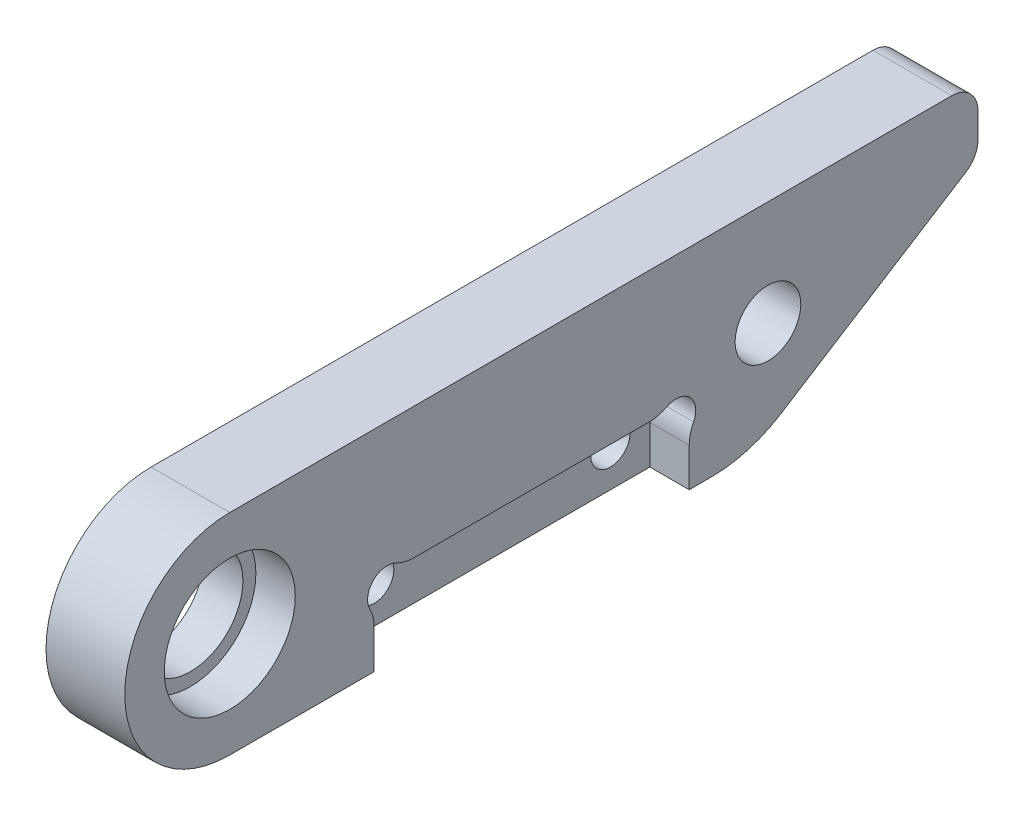
from build123d import *

# Parameters (mm, degrees)
SKETCH27_R          = 4
SKETCH27_R_2        = 2.5
BOSS_EXTRUDE1_DEPTH = 6
SKETCH33_R          = 4.99
CUT_EXTRUDE2_DEPTH  = 3
SKETCH34_W          = 24
SKETCH34_H          = 6
CUT_EXTRUDE3_DEPTH  = 3
SKETCH35_R          = 1.5
CUT_EXTRUDE4_DEPTH  = 3
FILLET1_R           = 3
CUT_EXTRUDE5_REACH  = 5
SKETCH36_R          = 1.5
FILLET3_R           = 2
FILLET4_R           = 10


with BuildPart() as part:
    # Sketch27 → Boss-Extrude1 (new body)
    with BuildSketch(Plane(origin=(0, 0, 0), x_dir=(0, 0, -1), z_dir=(1, 0, 0))):
        with BuildLine():
            Line((9, 50), (66, 50))
            Line((66, 50), (66, 45))
            Line((66, 45), (48.564398788, 34))
            Line((48.564398788, 34), (9, 34))
            ThreePointArc((9, 34), (1, 42), (9, 50))
        make_face()
        with Locations((9, 42)):
            Circle(SKETCH27_R, mode=Mode.SUBTRACT)
        with Locations((50, 42)):
            Circle(SKETCH27_R_2, mode=Mode.SUBTRACT)
    extrude(amount=BOSS_EXTRUDE1_DEPTH)

    # Sketch33 → Cut-Extrude2 (cut)
    with BuildSketch(Plane(origin=(6, 0, 0), x_dir=(0, 0, -1), z_dir=(1, 0, 0))):
        with Locations((9, 42)):
            Circle(SKETCH33_R)
    extrude(amount=-CUT_EXTRUDE2_DEPTH, mode=Mode.SUBTRACT)

    # Sketch34 → Cut-Extrude3 (cut)
    with BuildSketch(Plane(origin=(6, 0, 0), x_dir=(0, 0, -1), z_dir=(1, 0, 0))):
        with Locations((32, 37)):
            Rectangle(SKETCH34_W, SKETCH34_H)
    extrude(amount=-CUT_EXTRUDE3_DEPTH, mode=Mode.SUBTRACT)

    # Sketch35 → Cut-Extrude4 (cut)
    with BuildSketch(Plane(origin=(6, 0, 0), x_dir=(0, 0, -1), z_dir=(1, 0, 0))):
        with Locations((21, 39)):
            Circle(SKETCH35_R)
        with Locations((43, 39)):
            Circle(SKETCH35_R)
    extrude(amount=-CUT_EXTRUDE4_DEPTH, mode=Mode.SUBTRACT)

    # Fillet1
    fillet1_edges = [part.edges().sort_by_distance(p)[0] for p in [
        (4.5, 37.881966011, -20),
        (4.5, 40, -22.118033989),
        (4.5, 40, -41.881966011),
        (4.5, 37.881966011, -44),
    ]]
    fillet(fillet1_edges, radius=FILLET1_R)

    # Sketch36 → Cut-Extrude5 (cut, up to next)
    with BuildSketch(Plane(origin=(3, 0, 0), x_dir=(0, 0, -1), z_dir=(1, 0, 0)), mode=Mode.PRIVATE) as cut_extrude5_sk1:
        with Locations((23, 37)):
            Circle(SKETCH36_R)
    cut_extrude5_tool1 = extrude(cut_extrude5_sk1.sketch, amount=-CUT_EXTRUDE5_REACH, mode=Mode.PRIVATE) & part.part
    add(cut_extrude5_tool1.solids().sort_by_distance((3, 37, -23))[0], mode=Mode.SUBTRACT)
    # Sketch36 → Cut-Extrude5 (cut, up to next)
    with BuildSketch(Plane(origin=(3, 0, 0), x_dir=(0, 0, -1), z_dir=(1, 0, 0)), mode=Mode.PRIVATE) as cut_extrude5_sk2:
        with Locations((41, 37)):
            Circle(SKETCH36_R)
    cut_extrude5_tool2 = extrude(cut_extrude5_sk2.sketch, amount=-CUT_EXTRUDE5_REACH, mode=Mode.PRIVATE) & part.part
    add(cut_extrude5_tool2.solids().sort_by_distance((3, 37, -41))[0], mode=Mode.SUBTRACT)

    # Fillet3
    fillet3_edges = [part.edges().sort_by_distance(p)[0] for p in [
        (3, 50, -66),
        (3, 45, -66),
    ]]
    fillet(fillet3_edges, radius=FILLET3_R)

    # Fillet4
    fillet4_edges = [part.edges().sort_by_distance(p)[0] for p in [
        (3, 34, -48.564398788),
    ]]
    fillet(fillet4_edges, radius=FILLET4_R)


solid = part.part
